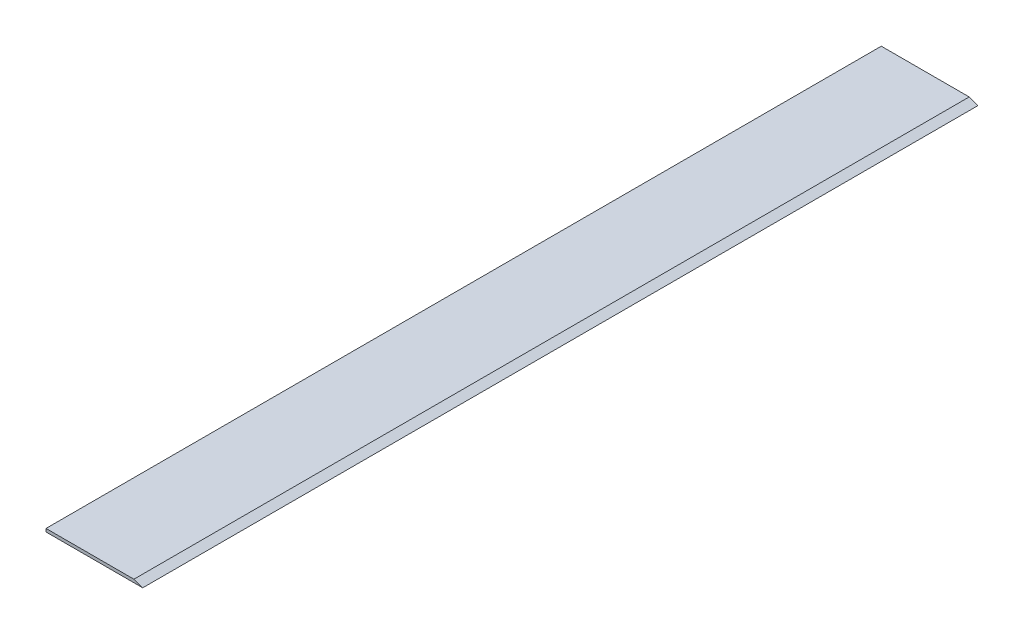
from build123d import *

# Parameters (mm, degrees)
SALIENTE_EXTRUIR1_DEPTH = 190


with BuildPart() as part:
    # Croquis1 → Saliente-Extruir1 (new body)
    with BuildSketch(Plane.XY):
        Polygon((0, 0), (22, 0), (20, 0.7), (0, 0.7), align=None)
    extrude(amount=SALIENTE_EXTRUIR1_DEPTH)


solid = part.part
